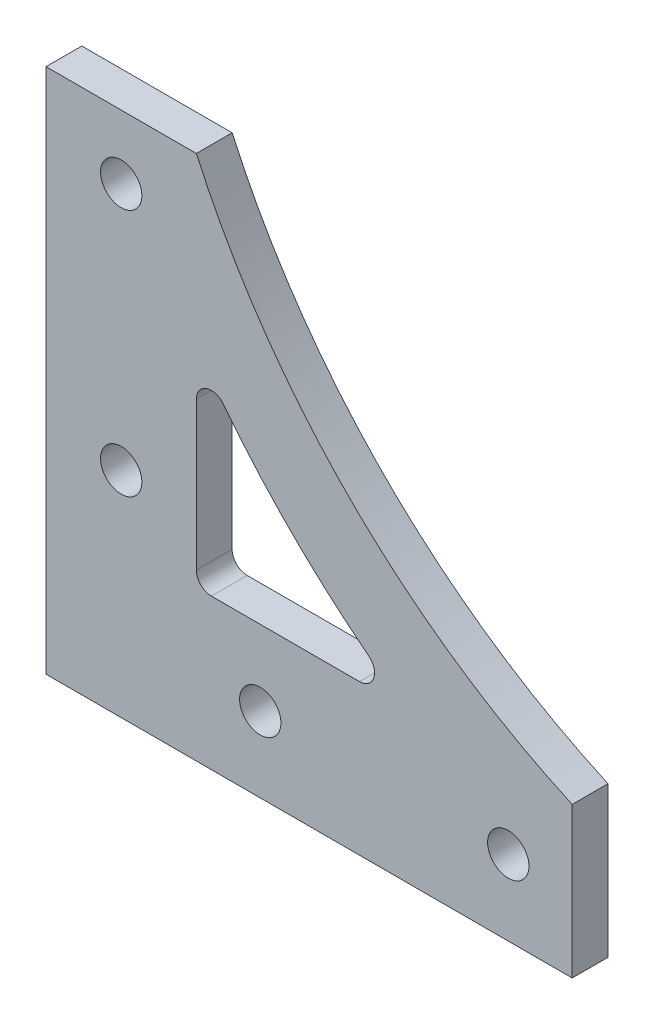
from build123d import *

# Parameters (mm, degrees)
SKETCH1_R           = 2.75
BOSS_EXTRUDE1_DEPTH = 4.7625


with BuildPart() as part:
    # Sketch1 → Boss-Extrude1 (new body)
    with BuildSketch(Plane.XY):
        with BuildLine():
            Line((0, 0), (70, 0))
            Line((70, 0), (70, 20))
            ThreePointArc((70, 20), (40.433104658, 40.433104658), (20, 70))
            Line((20, 70), (0, 70))
            Line((0, 70), (0, 0))
        make_face()
        with Locations((10, 61.5)):
            Circle(SKETCH1_R, mode=Mode.SUBTRACT)
        with Locations((10, 28.5)):
            Circle(SKETCH1_R, mode=Mode.SUBTRACT)
        with Locations((28.5, 10)):
            Circle(SKETCH1_R, mode=Mode.SUBTRACT)
        with Locations((61.5, 10)):
            Circle(SKETCH1_R, mode=Mode.SUBTRACT)
        with BuildLine():
            Line((20, 41.700381418), (20, 22))
            ThreePointArc((20, 22), (20.585786438, 20.585786438), (22, 20))
            Line((22, 20), (41.700381418, 20))
            ThreePointArc((41.700381418, 20), (43.591879783, 21.350204699), (42.929468168, 23.577766067))
            ThreePointArc((42.929468168, 23.577766067), (32.654930065, 32.654930065), (23.577766067, 42.929468168))
            ThreePointArc((23.577766067, 42.929468168), (21.350204699, 43.591879783), (20, 41.700381418))
        make_face(mode=Mode.SUBTRACT)
    extrude(amount=BOSS_EXTRUDE1_DEPTH)


solid = part.part
